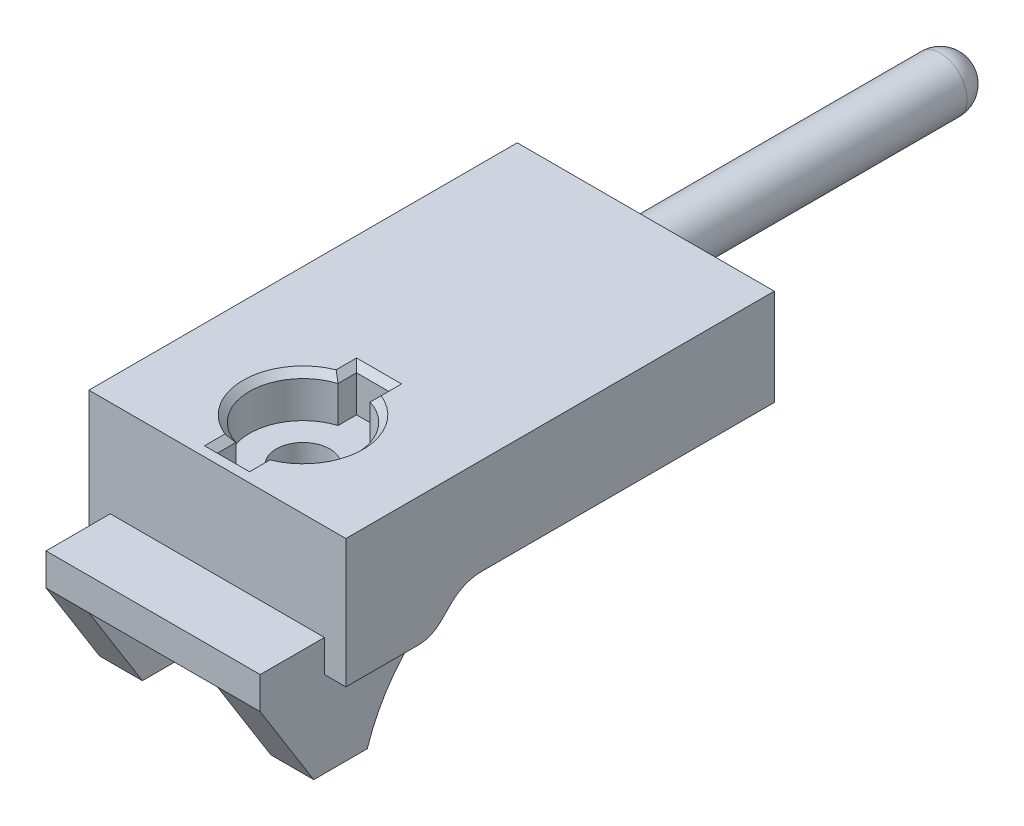
from build123d import *

# Parameters (mm, degrees)
SKETCH_1_W             = 12
SKETCH_1_H             = 23
EXTRUDE_1_DEPTH        = 10
SKETCH_3_W             = 12
SKETCH_3_H             = 3
CUT_EXTRUDE_1_DEPTH    = 4.5
SKETCH_4_W             = 1
SKETCH_4_H             = 3
CUT_EXTRUDE_2_DEPTH    = 11
CUT_EXTRUDE_3_DEPTH    = 6
CUT_EXTRUDE_4_DEPTH    = 1
FILLET_1_R             = 1.5
FILLET_2_R             = 2
FILLET_1_OF_MIRROR_1_R = 1.5
FILLET_2_OF_MIRROR_1_R = 2
SKETCH_7_W             = 6
SKETCH_7_H             = 11.5
CUT_EXTRUDE_5_DEPTH    = 4
SKETCH_8_W             = 8
SKETCH_8_H             = 16
CUT_EXTRUDE_6_DEPTH    = 8
SKETCH_9_R             = 2.5
CUT_EXTRUDE_7_DEPTH    = 4
EXTRUDE_2_DEPTH        = 2
SKETCH_11_R            = 1.25
CUT_EXTRUDE_8_DEPTH    = 5
CUT_EXTRUDE_9_DEPTH    = 2
CHAMFER_1_SIZE         = 0.3
SKETCH_13_R            = 1.25
EXTRUDE_3_DEPTH        = 15
FILLET_3_R             = 1.25


with BuildPart() as part:
    # 草图1 → 凸台-拉伸1 (new body)
    with BuildSketch(Plane(origin=(0, 0, 0), x_dir=(1, 0, 0), z_dir=(0, 1, 0))):
        Rectangle(SKETCH_1_W, SKETCH_1_H)
    extrude(amount=EXTRUDE_1_DEPTH)

    # 草图3 → 切除-拉伸1 (cut)
    with BuildSketch(Plane(origin=(0, 10, 0), x_dir=(1, 0, 0), z_dir=(0, 1, 0))):
        with Locations((0, -10)):
            Rectangle(SKETCH_3_W, SKETCH_3_H)
    extrude(amount=-CUT_EXTRUDE_1_DEPTH, mode=Mode.SUBTRACT)

    # 草图4 → 切除-拉伸2 (cut, through all)
    with BuildSketch(Plane(origin=(0, 0, 0), x_dir=(1, 0, 0), z_dir=(0, 1, 0))):
        with Locations((5.5, -10)):
            Rectangle(SKETCH_4_W, SKETCH_4_H)
        with Locations((-5.5, -10)):
            Rectangle(SKETCH_4_W, SKETCH_4_H)
    extrude(amount=CUT_EXTRUDE_2_DEPTH, mode=Mode.SUBTRACT)

    # 草图5 → 切除-拉伸3 (cut, symmetric)
    with BuildSketch(Plane(origin=(0, 0, 0), x_dir=(0, 0, -1), z_dir=(1, 0, 0))):
        with BuildLine():
            Line((11.5, 5.5), (0, 5.5))
            ThreePointArc((0, 5.5), (-4.042500986, 3.686592074), (-6.5, 0))
            Line((-6.5, 0), (11.5, 0))
            Line((11.5, 0), (11.5, 5.5))
        make_face()
        Polygon((-9, 0), (-11.5, 4), (-11.5, 0), align=None)
    extrude(amount=CUT_EXTRUDE_3_DEPTH, both=True, mode=Mode.SUBTRACT)

    # 草图6 → 切除-拉伸4 (cut)
    with BuildSketch(Plane(origin=(6, 0, 0), x_dir=(0, 0, -1), z_dir=(1, 0, 0))):
        with BuildLine():
            Line((-8.5, 4), (-4.5, 4))
            Line((-4.5, 4), (-3, 5.5))
            Line((-3, 5.5), (0, 5.5))
            ThreePointArc((0, 5.5), (-4.042500986, 3.686592074), (-6.5, 0))
            Line((-6.5, 0), (-8.5, 0))
            Line((-8.5, 0), (-8.5, 4))
        make_face()
    cut_extrude_4 = extrude(amount=-CUT_EXTRUDE_4_DEPTH, mode=Mode.SUBTRACT)

    # 圆角1
    fillet_1_edges = [part.edges().sort_by_distance(p)[0] for p in [
        (5.5, 4, 4.5),
    ]]
    fillet(fillet_1_edges, radius=FILLET_1_R)

    # 圆角2
    fillet_2_edges = [part.edges().sort_by_distance(p)[0] for p in [
        (5.5, 5.5, 3),
    ]]
    fillet(fillet_2_edges, radius=FILLET_2_R)

    # 镜向1: 切除-拉伸4 across plane
    add(cut_extrude_4.mirror(Plane(origin=(0, 0, 0), x_dir=(0, 0, 1), z_dir=(1, 0, 0))), mode=Mode.SUBTRACT)

    # 圆角1 of 镜向1
    fillet_1_of_mirror_1_edges = [part.edges().sort_by_distance(p)[0] for p in [
        (-5.5, 4, 4.5),
    ]]
    fillet(fillet_1_of_mirror_1_edges, radius=FILLET_1_OF_MIRROR_1_R)

    # 圆角2 of 镜向1
    fillet_2_of_mirror_1_edges = [part.edges().sort_by_distance(p)[0] for p in [
        (-5.5, 5.5, 3),
    ]]
    fillet(fillet_2_of_mirror_1_edges, radius=FILLET_2_OF_MIRROR_1_R)

    # 草图7 → 切除-拉伸5 (cut)
    with BuildSketch(Plane(origin=(0, 0, 0), x_dir=(1, 0, 0), z_dir=(0, 1, 0))):
        with Locations((0, -5.75)):
            Rectangle(SKETCH_7_W, SKETCH_7_H)
    extrude(amount=CUT_EXTRUDE_5_DEPTH, mode=Mode.SUBTRACT)

    # 草图8 → 切除-拉伸6 (cut)
    with BuildSketch(Plane(origin=(0, 0, 0), x_dir=(1, 0, 0), z_dir=(0, 1, 0))):
        with Locations((0, 1.5)):
            Rectangle(SKETCH_8_W, SKETCH_8_H)
    extrude(amount=CUT_EXTRUDE_6_DEPTH, mode=Mode.SUBTRACT)

    # 草图9 → 切除-拉伸7 (cut)
    with BuildSketch(Plane.XZ.offset(-4)):
        with Locations((0, 4.5)):
            Circle(SKETCH_9_R)
    extrude(amount=-CUT_EXTRUDE_7_DEPTH, mode=Mode.SUBTRACT)

    # 草图10 → 凸台-拉伸2 (add)
    with BuildSketch(Plane.XZ.offset(-8)):
        with BuildLine():
            Line((2, 1), (3, 2))
            Line((3, 2), (3, 6.5))
            Line((3, 6.5), (1.5, 6.5))
            ThreePointArc((1.5, 6.5), (0, 7), (-1.5, 6.5))
            Line((-1.5, 6.5), (-3, 6.5))
            Line((-3, 6.5), (-3, 2))
            Line((-3, 2), (-2, 1))
            Line((-2, 1), (-2, -0.5))
            Line((-2, -0.5), (2, -0.5))
            Line((2, -0.5), (2, 1))
        make_face()
    extrude(amount=EXTRUDE_2_DEPTH)

    # 草图11 → 切除-拉伸8 (cut, through all)
    with BuildSketch(Plane.XZ.offset(-6)):
        with Locations((0, 4.5)):
            Circle(SKETCH_11_R)
    extrude(amount=-CUT_EXTRUDE_8_DEPTH, mode=Mode.SUBTRACT)

    # 草图12 → 切除-拉伸9 (cut)
    with BuildSketch(Plane(origin=(0, 10, 0), x_dir=(1, 0, 0), z_dir=(0, 1, 0))):
        with BuildLine():
            Line((-0.75, -1.25), (0.75, -1.25))
            Line((0.75, -1.25), (0.75, -2.115151996))
            ThreePointArc((0.75, -2.115151996), (2.5, -4.5), (0.75, -6.884848004))
            Line((0.75, -6.884848004), (0.75, -7.75))
            Line((0.75, -7.75), (-0.75, -7.75))
            Line((-0.75, -7.75), (-0.75, -6.884848004))
            ThreePointArc((-0.75, -6.884848004), (-2.5, -4.5), (-0.75, -2.115151996))
            Line((-0.75, -2.115151996), (-0.75, -1.25))
        make_face()
    extrude(amount=-CUT_EXTRUDE_9_DEPTH, mode=Mode.SUBTRACT)

    # 倒角1
    chamfer_1_edges = [part.edges().sort_by_distance(p)[0] for p in [
        (2.5, 10, 4.5),
        (0.75, 10, 1.682575998),
        (0, 10, 1.25),
        (-0.75, 10, 1.682575998),
        (-2.5, 10, 4.5),
        (-0.75, 10, 7.317424002),
        (0, 10, 7.75),
        (0.75, 10, 7.317424002),
    ]]
    chamfer(chamfer_1_edges, length=CHAMFER_1_SIZE)

    # 草图13 → 凸台-拉伸3 (add)
    with BuildSketch(Plane(origin=(0, 0, -11.5), x_dir=(-1, 0, 0), z_dir=(0, 0, -1))):
        with Locations((0, 8.5)):
            Circle(SKETCH_13_R)
    extrude(amount=EXTRUDE_3_DEPTH)

    # 圆角3
    fillet_3_edges = [part.edges().sort_by_distance(p)[0] for p in [
        (1.25, 8.5, -26.5),
    ]]
    fillet(fillet_3_edges, radius=FILLET_3_R)


solid = part.part
